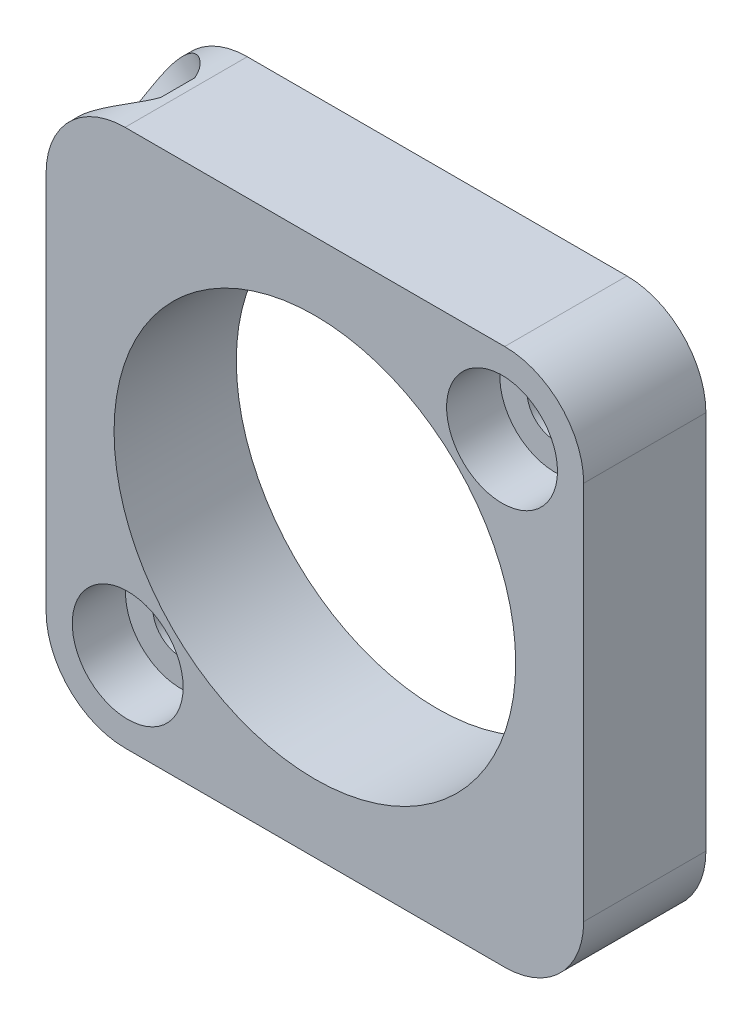
from build123d import *

# Parameters (mm, degrees)
SKETCH1_W                                     = 3.5
SKETCH1_H                                     = 9.25
CBORE_FOR_0_SOCKET_HEAD_CAP_SCREW1_AT_2_COUNT = 2
CBORE_FOR_0_SOCKET_HEAD_CAP_SCREW1_AT_2_PITCH = 15.15867233
SKETCH5_OUTSIDE_W                             = 40.514
SKETCH5_OUTSIDE_H                             = 40.514
SKETCH5_OUTSIDE_W_2                           = 15.3924
SKETCH5_OUTSIDE_H_2                           = 15.3924
CUT_EXTRUDE1_DEPTH                            = 10
FILLET1_R                                     = 2.2606
SKETCH8_R                                     = 1.5
CUT_EXTRUDE2_DEPTH                            = 0.5
F_2_56_TAPPED_HOLE1_REACH                     = 22.332
F_2_56_TAPPED_HOLE1_BORE_R                    = 0.889


with BuildPart() as part:
    # Sketch1 → Revolve1 (revolve)
    with BuildSketch(Plane(origin=(0, 0, 0), x_dir=(0, 0, -1), z_dir=(1, 0, 0)), mode=Mode.PRIVATE) as revolve1_sk:
        with Locations((-1.75, 10.375)):
            Rectangle(SKETCH1_W, SKETCH1_H)
    revolve(revolve1_sk.sketch.rotate(Axis((0, 0, 0), (0, 0, -1)), 90), axis=Axis((0, 0, 0), (0, 0, -1)))  # turned: the seam where the file's is

    # Sketch3 → CBORE for #0 Socket Head Cap Screw1 (revolve, cut)
    with BuildSketch(Plane(origin=(5.359399999, 5.359399999, 3.5), x_dir=(0, -1, 0), z_dir=(1, 0, 0))):
        Polygon((0, 0), (0, 3.5), (1.44145, 3.5), (0.80645, 2.865), (0.80645, 1.524), (1.5875, 1.524), (1.5875, 0), align=None)
    cbore_for_0_socket_head_cap_screw1 = revolve(axis=Axis((5.359399999, 5.359399999, 9.85), (0, 0, -1)), mode=Mode.SUBTRACT)

    # CBORE for #0 Socket Head Cap Screw1 at 2: CBORE for #0 Socket Head Cap Screw1 ×2
    with Locations(*[Vector(-0.707106781, -0.707106781, 0) * (i * CBORE_FOR_0_SOCKET_HEAD_CAP_SCREW1_AT_2_PITCH) for i in range(1, CBORE_FOR_0_SOCKET_HEAD_CAP_SCREW1_AT_2_COUNT)]):
        add(cbore_for_0_socket_head_cap_screw1, mode=Mode.SUBTRACT)

    # Sketch5 outside → Cut-Extrude1 (cut)
    with BuildSketch(Plane.XY.offset(3.5)):
        Rectangle(SKETCH5_OUTSIDE_W, SKETCH5_OUTSIDE_H)
        Rectangle(SKETCH5_OUTSIDE_W_2, SKETCH5_OUTSIDE_H_2, mode=Mode.SUBTRACT)
    extrude(amount=-CUT_EXTRUDE1_DEPTH, mode=Mode.SUBTRACT)

    # Fillet1
    fillet1_edges = [part.edges().sort_by_distance(p)[0] for p in [
        (-7.6962, 7.6962, 1.75),
        (7.6962, 7.6962, 1.75),
        (7.6962, -7.6962, 1.75),
        (-7.6962, -7.6962, 1.75),
    ]]
    fillet(fillet1_edges, radius=FILLET1_R)

    # Sketch8 → Cut-Extrude2 (cut)
    with BuildSketch(Plane(origin=(-7.03408559, 7.03408559, 1.75), x_dir=(0, 0, 1), z_dir=(-0.707106781, 0.707106781, 0))):
        Circle(SKETCH8_R)
    extrude(amount=-CUT_EXTRUDE2_DEPTH, mode=Mode.SUBTRACT)

    # #2-56 Tapped Hole1 bore → #2-56 Tapped Hole1 (cut, up to next)
    with BuildSketch(Plane(origin=(-6.680532199, 6.680532199, 0), x_dir=(-0.707106781, -0.707106781, 0), z_dir=(-0.707106781, 0.707106781, 0)), mode=Mode.PRIVATE) as f_2_56_tapped_hole1_sk1:
        with Locations((0, 1.75)):
            Circle(F_2_56_TAPPED_HOLE1_BORE_R)
    f_2_56_tapped_hole1_tool1 = extrude(f_2_56_tapped_hole1_sk1.sketch, amount=-F_2_56_TAPPED_HOLE1_REACH, mode=Mode.PRIVATE) & part.part
    add(f_2_56_tapped_hole1_tool1.solids().sort_by_distance((-6.680532, 6.680532, 1.75))[0], mode=Mode.SUBTRACT)


solid = part.part
